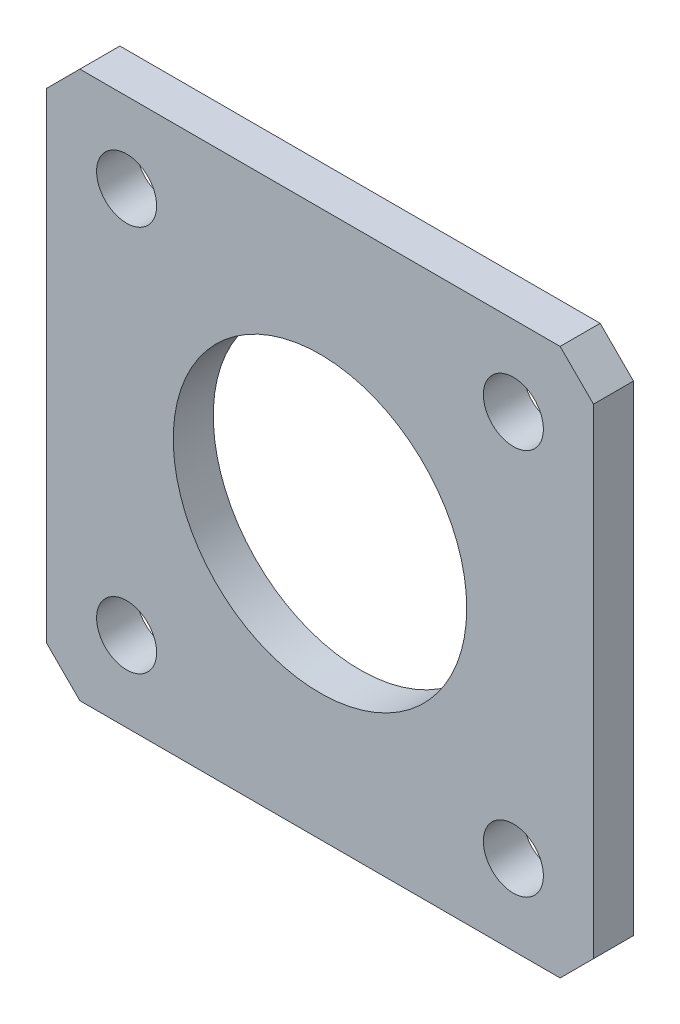
from build123d import *

# Parameters (mm, degrees)
SKETCH_1_W          = 41
SKETCH_1_H          = 41
SKETCH_1_R          = 11
EXTRUDE_1_DEPTH     = 3
SKETCH_4_R          = 2.25
CUT_EXTRUDE_2_DEPTH = 4
CHAMFER_1_SIZE      = 2.5


with BuildPart() as part:
    # Эскиз1 → Вытянуть1 (new body)
    with BuildSketch(Plane.XY):
        Rectangle(SKETCH_1_W, SKETCH_1_H)
        Circle(SKETCH_1_R, mode=Mode.SUBTRACT)
    extrude(amount=EXTRUDE_1_DEPTH)

    # Эскиз4 → Вытянуть2 (cut, through all)
    with BuildSketch(Plane.XY.offset(3)):
        with Locations((-14.495689014, 14.495689014)):
            Circle(SKETCH_4_R)
        with Locations((14.495689014, 14.495689014)):
            Circle(SKETCH_4_R)
        with Locations((14.495689014, -14.495689014)):
            Circle(SKETCH_4_R)
        with Locations((-14.495689014, -14.495689014)):
            Circle(SKETCH_4_R)
    extrude(amount=-CUT_EXTRUDE_2_DEPTH, mode=Mode.SUBTRACT)

    # Фаска1
    chamfer_1_edges = [part.edges().sort_by_distance(p)[0] for p in [
        (20.5, -20.5, 1.5),
        (-20.5, -20.5, 1.5),
        (-20.5, 20.5, 1.5),
        (20.5, 20.5, 1.5),
    ]]
    chamfer(chamfer_1_edges, length=CHAMFER_1_SIZE)


solid = part.part
